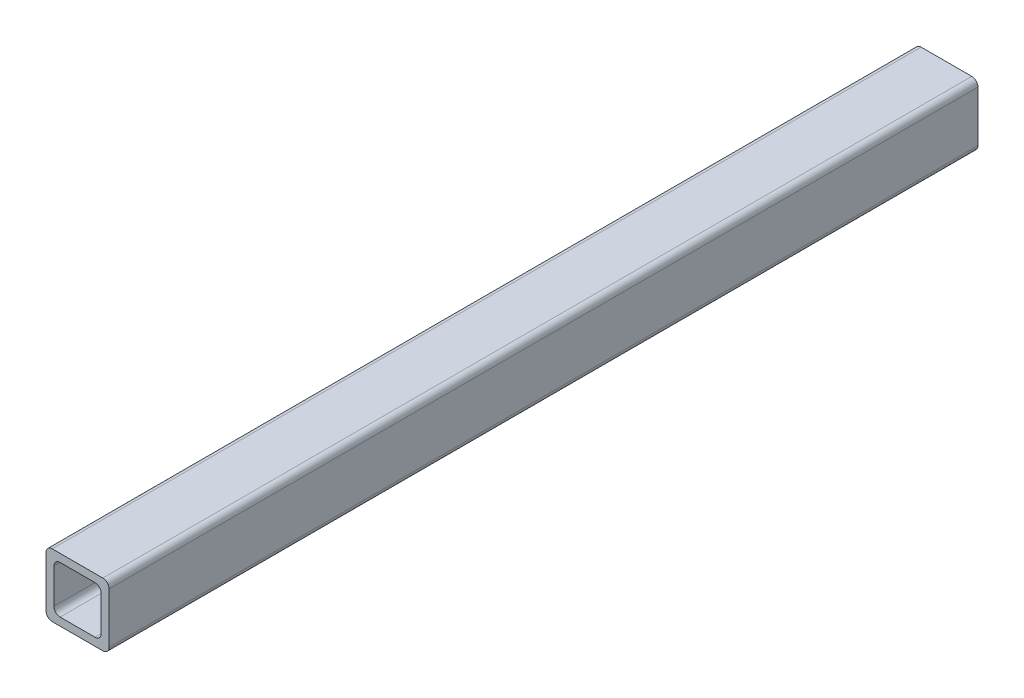
from build123d import *

# Parameters (mm, degrees)
SALIENTE_EXTRUIR1_DEPTH = 350


with BuildPart() as part:
    # Croquis1 → Saliente-Extruir1 (new body)
    with BuildSketch(Plane.XY):
        with BuildLine():
            Line((-10.2, -12.7), (10.2, -12.7))
            ThreePointArc((10.2, -12.7), (11.967766953, -11.967766953), (12.7, -10.2))
            Line((12.7, -10.2), (12.7, 10.2))
            ThreePointArc((12.7, 10.2), (11.967766953, 11.967766953), (10.2, 12.7))
            Line((10.2, 12.7), (-10.2, 12.7))
            ThreePointArc((-10.2, 12.7), (-11.967766953, 11.967766953), (-12.7, 10.2))
            Line((-12.7, 10.2), (-12.7, -10.2))
            ThreePointArc((-12.7, -10.2), (-11.967766953, -11.967766953), (-10.2, -12.7))
        make_face()
        with BuildLine():
            Line((-7.025, -9.525), (7.025, -9.525))
            ThreePointArc((7.025, -9.525), (8.792766953, -8.792766953), (9.525, -7.025))
            Line((9.525, -7.025), (9.525, 7.025))
            ThreePointArc((9.525, 7.025), (8.792766953, 8.792766953), (7.025, 9.525))
            Line((7.025, 9.525), (-7.025, 9.525))
            ThreePointArc((-7.025, 9.525), (-8.792766953, 8.792766953), (-9.525, 7.025))
            Line((-9.525, 7.025), (-9.525, -7.025))
            ThreePointArc((-9.525, -7.025), (-8.792766953, -8.792766953), (-7.025, -9.525))
        make_face(mode=Mode.SUBTRACT)
    extrude(amount=SALIENTE_EXTRUIR1_DEPTH)


solid = part.part
